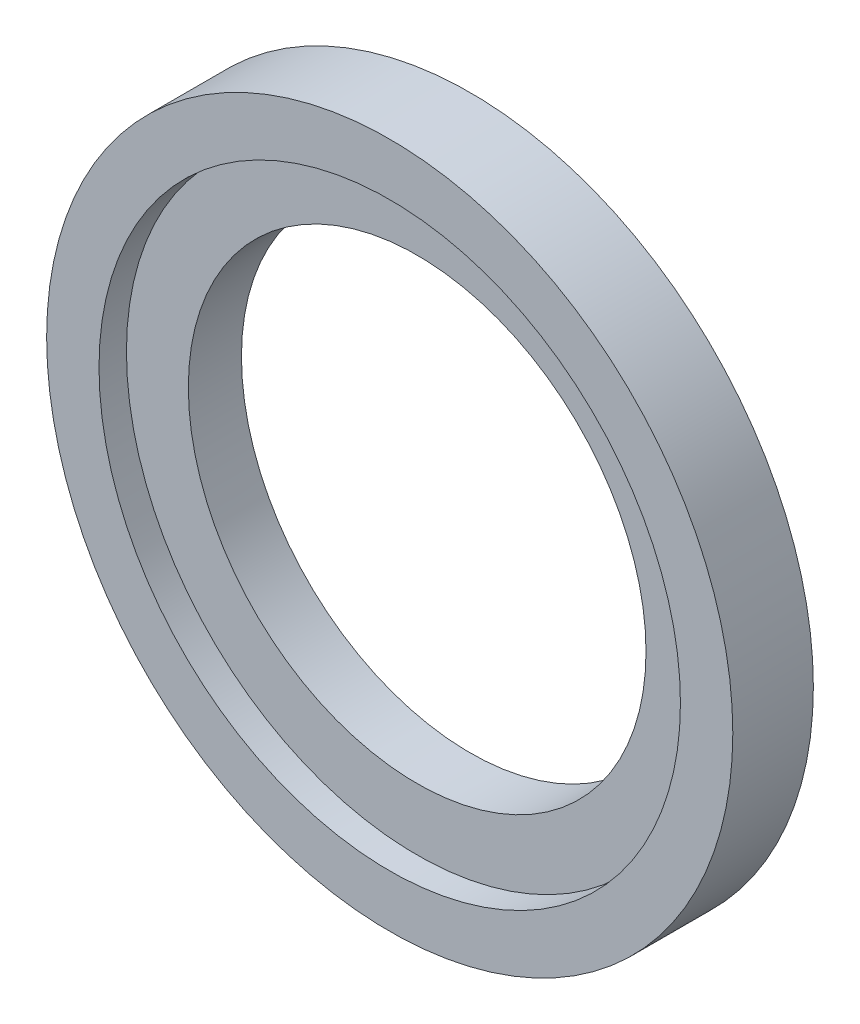
from build123d import *

# Parameters (mm, degrees)
SKETCH1_R           = 25
BOSS_EXTRUDE1_DEPTH = 5.87
SKETCH2_R           = 16.675
CUT_EXTRUDE1_DEPTH  = 6.87
SKETCH3_R           = 21.184132597
CUT_EXTRUDE2_DEPTH  = 2


with BuildPart() as part:
    # Sketch1 → Boss-Extrude1 (new body)
    with BuildSketch(Plane.XY):
        Circle(SKETCH1_R)
    extrude(amount=BOSS_EXTRUDE1_DEPTH)

    # Sketch2 → Cut-Extrude1 (cut, through all)
    with BuildSketch(Plane(origin=(0, 0, 0), x_dir=(-1, 0, 0), z_dir=(0, 0, -1))):
        Circle(SKETCH2_R)
    extrude(amount=-CUT_EXTRUDE1_DEPTH, mode=Mode.SUBTRACT)

    # Sketch3 → Cut-Extrude2 (cut)
    with BuildSketch(Plane.XY.offset(5.87)):
        Circle(SKETCH3_R)
    extrude(amount=-CUT_EXTRUDE2_DEPTH, mode=Mode.SUBTRACT)


solid = part.part
